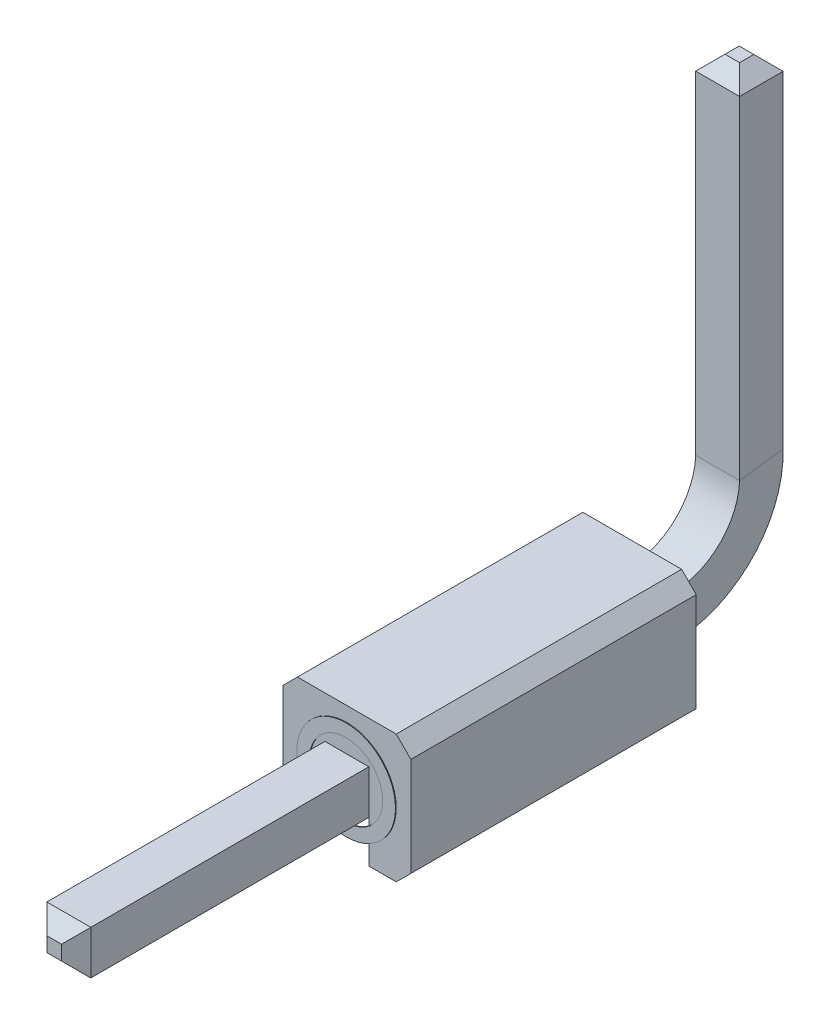
from build123d import *

# Parameters (mm, degrees)
BOSS_EXTRU_1_DEPTH           = 2.8
BOSS_EXTRU_1_DEPTH_BACK      = 1.1
ESQUISSE1_W                  = 0.6
ESQUISSE1_H                  = 0.6
ESQUISSE2_W                  = 0.6
ESQUISSE2_H                  = 0.575
ENL_V_MAT_EXTRU_1_DEPTH      = 1
BOSS_EXTRU_2_DEPTH           = 4
BOSS_EXTRU_2_DEPTH_BACK      = 4
ESQUISSE3_W                  = 0.6
ESQUISSE3_H                  = 0.6
ESQUISSE4_R                  = 0.674645205
ESQUISSE4_R_2                = 0.5
BOSS_EXTRU_3_DEPTH           = 0.01
ESQUISSE6_W                  = 0.6
ESQUISSE6_H                  = 0.6
ENL_V_MAT_EXTRU_2_DEPTH      = 0.1
ENL_V_MAT_EXTRU_2_DEPTH_BACK = 0.1
ESQUISSE5_W                  = 0.6
ESQUISSE5_H                  = 0.6
CHANFREIN1_SIZE              = 0.2


with BuildPart() as part:
    # Esquisse1 → Boss.-Extru.1 (new, two sides: drawn at the far end of the back side and taken through both)
    with BuildSketch(Plane.XY.offset(-BOSS_EXTRU_1_DEPTH_BACK)):
        Polygon((-0.675, 0.875), (-0.875, 0.675), (-0.875, -0.675), (-0.675, -0.875), (0.675, -0.875), (0.875, -0.675), (0.875, 0.675), (0.675, 0.875), align=None)
        Rectangle(ESQUISSE1_W, ESQUISSE1_H, mode=Mode.SUBTRACT)
    extrude(amount=BOSS_EXTRU_1_DEPTH + BOSS_EXTRU_1_DEPTH_BACK)

    # Esquisse2 → Enlèv. mat.-Extru.1 (cut)
    with BuildSketch(Plane.XY.offset(2.8)):
        with Locations((0, -0.5875)):
            Rectangle(ESQUISSE2_W, ESQUISSE2_H)
    extrude(amount=-ENL_V_MAT_EXTRU_1_DEPTH, mode=Mode.SUBTRACT)

    # Esquisse3 → Boss.-Extru.2 (add, two sides: drawn at the far end of the back side and taken through both)
    with BuildSketch(Plane.XY.offset(2.8).offset(-BOSS_EXTRU_2_DEPTH_BACK)):
        Rectangle(ESQUISSE3_W, ESQUISSE3_H)
    extrude(amount=BOSS_EXTRU_2_DEPTH + BOSS_EXTRU_2_DEPTH_BACK)

    # Esquisse4 → Boss.-Extru.3 (add)
    with BuildSketch(Plane.XY.offset(2.8)):
        Circle(ESQUISSE4_R)
        Circle(ESQUISSE4_R_2, mode=Mode.SUBTRACT)
    extrude(amount=BOSS_EXTRU_3_DEPTH)

    # Balayage1: sweep along a path in Esquisse25
    with BuildLine(Plane(origin=(0, 0, 0), x_dir=(0, 0, -1), z_dir=(1, 0, 0))) as balayage1_path:
        Line((2.565105715, 6), (2.565105715, 1.192347565))
        ThreePointArc((2.565105715, 1.192347565), (2.153394049, 0.286090658), (1.2, 0))
    # Esquisse6 → Balayage1 (sweep)
    with BuildSketch(Plane(origin=(0, 0, -1.2), x_dir=(-1, 0, 0), z_dir=(0, 0, -1))):
        Rectangle(ESQUISSE6_W, ESQUISSE6_H)
    sweep(path=balayage1_path.line)

    # Esquisse5 → Enlèv. mat.-Extru.2 (cut, two sides: drawn at the far end of the back side and taken through both)
    with BuildSketch(Plane(origin=(0, 6, 0), x_dir=(1, 0, 0), z_dir=(0, 1, 0)).offset(-ENL_V_MAT_EXTRU_2_DEPTH_BACK)):
        with Locations((0, 2.565105715)):
            Rectangle(ESQUISSE5_W, ESQUISSE5_H)
    extrude(amount=ENL_V_MAT_EXTRU_2_DEPTH + ENL_V_MAT_EXTRU_2_DEPTH_BACK, mode=Mode.SUBTRACT)

    # Chanfrein1
    chanfrein1_edges = [part.edges().sort_by_distance(p)[0] for p in [
        (0, -0.3, 6.8),
        (-0.3, 0, 6.8),
        (0, 0.3, 6.8),
        (0.3, 0, 6.8),
        (0, 5.9, -2.267831149),
        (-0.3, 5.9, -2.565105715),
        (0, 5.9, -2.862380281),
        (0.3, 5.9, -2.565105715),
    ]]
    chamfer(chanfrein1_edges, length=CHANFREIN1_SIZE)


solid = part.part
